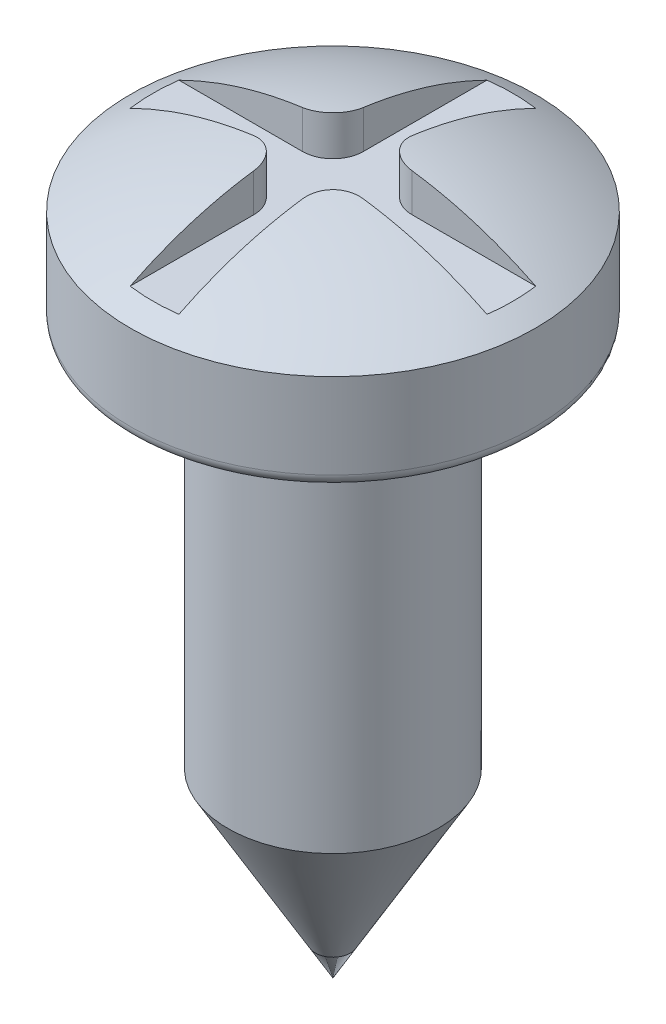
from build123d import *

# Parameters (mm, degrees)
CORTAR_EXTRUIR1_START = -1.8
CORTAR_EXTRUIR1_DEPTH = 3


with BuildPart() as part:
    # Croquis1 → Revolución1 (revolve)
    with BuildSketch(Plane.XY):
        with BuildLine():
            Line((0, 0), (0, 11.8))
            ThreePointArc((0, 11.8), (1.722325826, 11.57102319), (3.325, 10.9))
            Line((3.325, 10.9), (3.325, 9.5))
            ThreePointArc((3.325, 9.5), (3.266421356, 9.358578644), (3.125, 9.3))
            Line((3.125, 9.3), (1.725, 9.3))
            Line((1.725, 9.3), (1.725, 2.987787643))
            Line((1.725, 2.987787643), (0, 0))
        make_face()
    revolve(axis=Axis((0, 0, 0), (0, 1, 0)))

    # Croquis2 → Cortar-Extruir1 (cut)
    with BuildSketch(Plane.XZ.offset(-9.3).offset(CORTAR_EXTRUIR1_START)):
        with BuildLine():
            Line((-0.4, 3.2), (-0.4, 0.9))
            ThreePointArc((-0.4, 0.9), (-0.546446609, 0.546446609), (-0.9, 0.4))
            Line((-0.9, 0.4), (-3.2, 0.4))
            Line((-3.2, 0.4), (-3.2, -0.4))
            Line((-3.2, -0.4), (-0.9, -0.4))
            ThreePointArc((-0.9, -0.4), (-0.546446609, -0.546446609), (-0.4, -0.9))
            Line((-0.4, -0.9), (-0.4, -3.2))
            Line((-0.4, -3.2), (0.4, -3.2))
            Line((0.4, -3.2), (0.4, -0.9))
            ThreePointArc((0.4, -0.9), (0.546446609, -0.546446609), (0.9, -0.4))
            Line((0.9, -0.4), (3.2, -0.4))
            Line((3.2, -0.4), (3.2, 0.4))
            Line((3.2, 0.4), (0.9, 0.4))
            ThreePointArc((0.9, 0.4), (0.546446609, 0.546446609), (0.4, 0.9))
            Line((0.4, 0.9), (0.4, 3.2))
            Line((0.4, 3.2), (-0.4, 3.2))
        make_face()
    extrude(amount=-CORTAR_EXTRUIR1_DEPTH, mode=Mode.SUBTRACT)


solid = part.part
